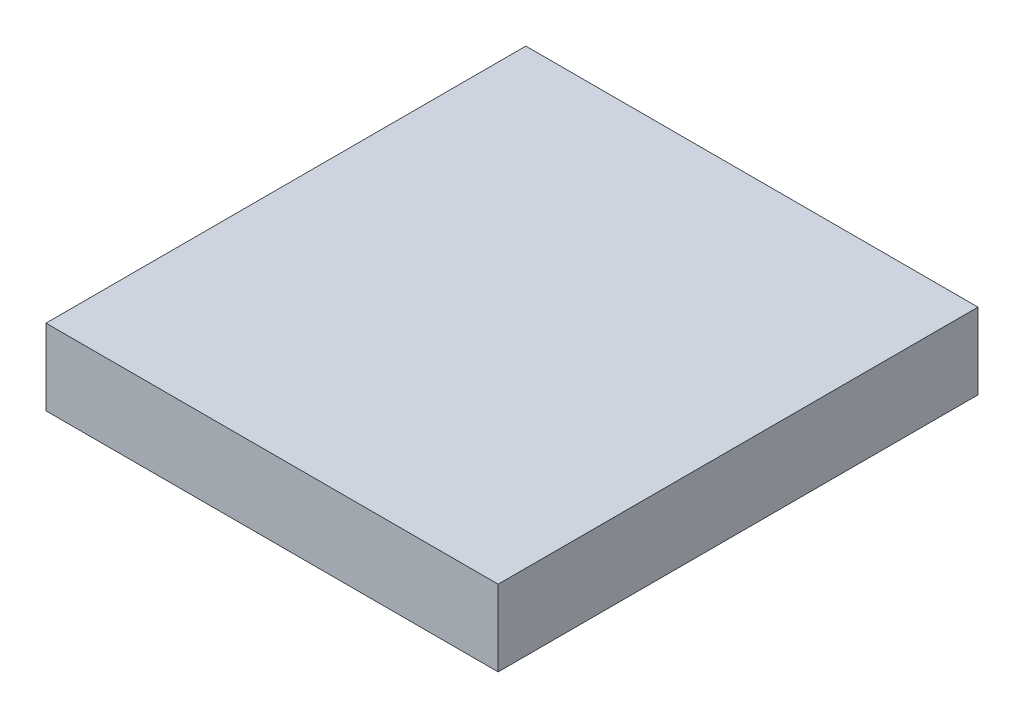
from build123d import *

# Parameters (mm, degrees)
SKETCH_1_W      = 238
SKETCH_1_H      = 252.580549317
EXTRUDE_1_DEPTH = 40


with BuildPart() as part:
    # Эскиз1 → Бобышка-Вытянуть1 (new body)
    with BuildSketch(Plane(origin=(0, 0, 0), x_dir=(1, 0, 0), z_dir=(0, 1, 0))):
        with Locations((119, 126.290274659)):
            Rectangle(SKETCH_1_W, SKETCH_1_H)
    extrude(amount=EXTRUDE_1_DEPTH)


solid = part.part
